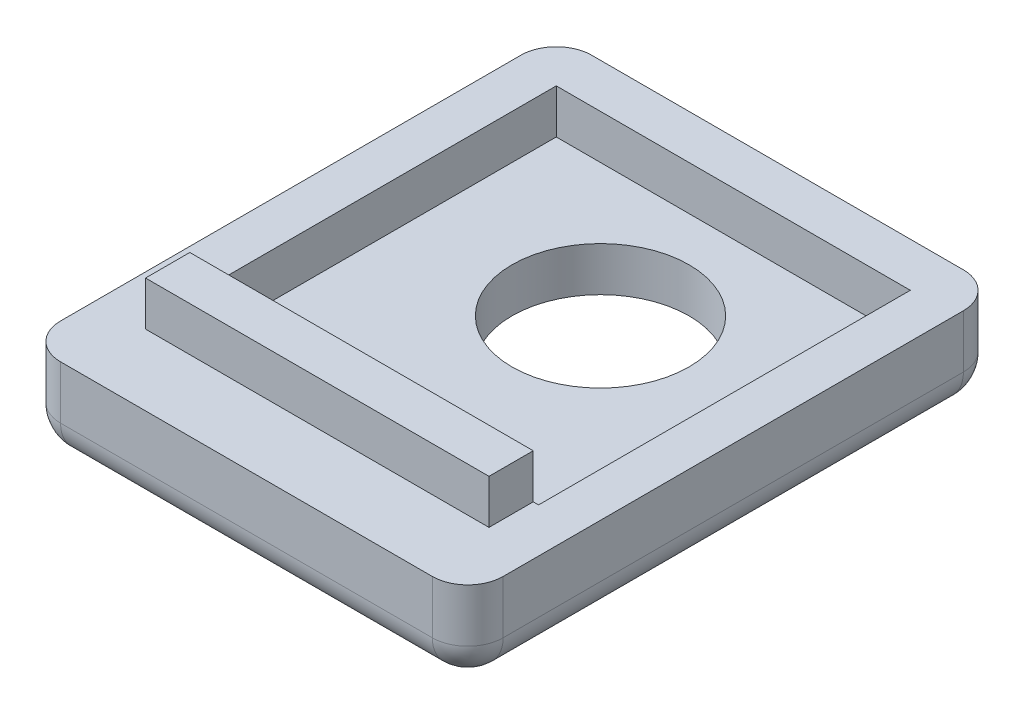
from build123d import *

# Parameters (mm, degrees)
SKETCH1_W           = 25
SKETCH1_H           = 30
BOSS_EXTRUDE1_DEPTH = 2.5
SKETCH3_W           = 25
SKETCH3_H           = 30
SKETCH3_W_2         = 20
SKETCH3_H_2         = 21
BOSS_EXTRUDE2_DEPTH = 2.5
SKETCH5_R           = 5
CUT_EXTRUDE1_DEPTH  = 2.5
FILLET2_R           = 2
SKETCH6_W           = 19.4
SKETCH6_H           = 2.5
BOSS_EXTRUDE4_DEPTH = 2.5


with BuildPart() as part:
    # Sketch1 → Boss-Extrude1 (new body)
    with BuildSketch(Plane(origin=(0, 0, 0), x_dir=(1, 0, 0), z_dir=(0, 1, 0))):
        Rectangle(SKETCH1_W, SKETCH1_H)
    extrude(amount=BOSS_EXTRUDE1_DEPTH)

    # Sketch3 → Boss-Extrude2 (add)
    with BuildSketch(Plane(origin=(0, 2.5, 0), x_dir=(1, 0, 0), z_dir=(0, 1, 0))):
        Rectangle(SKETCH3_W, SKETCH3_H)
        with Locations((0, 2)):
            Rectangle(SKETCH3_W_2, SKETCH3_H_2, mode=Mode.SUBTRACT)
    extrude(amount=BOSS_EXTRUDE2_DEPTH)

    # Sketch5 → Cut-Extrude1 (cut)
    with BuildSketch(Plane(origin=(0, 2.5, 0), x_dir=(1, 0, 0), z_dir=(0, 1, 0))):
        with Locations(Location((0, 5, 0), (0, 0, 270))):  # turned: the seam where the file's is
            Circle(SKETCH5_R)
    extrude(amount=-CUT_EXTRUDE1_DEPTH, mode=Mode.SUBTRACT)

    # Fillet2
    fillet2_edges = [part.edges().sort_by_distance(p)[0] for p in [
        (0, 0, 15),
        (-12.5, 0, 0),
        (0, 0, -15),
        (12.5, 0, 0),
        (12.5, 2.5, 15),
        (-12.5, 2.5, 15),
        (-12.5, 2.5, -15),
        (12.5, 2.5, -15),
    ]]
    fillet(fillet2_edges, radius=FILLET2_R)

    # Sketch6 → Boss-Extrude4 (add)
    with BuildSketch(Plane(origin=(0, 5, 0), x_dir=(1, 0, 0), z_dir=(0, 1, 0))):
        with Locations((0, -9.75)):
            Rectangle(SKETCH6_W, SKETCH6_H)
    extrude(amount=BOSS_EXTRUDE4_DEPTH)


solid = part.part
